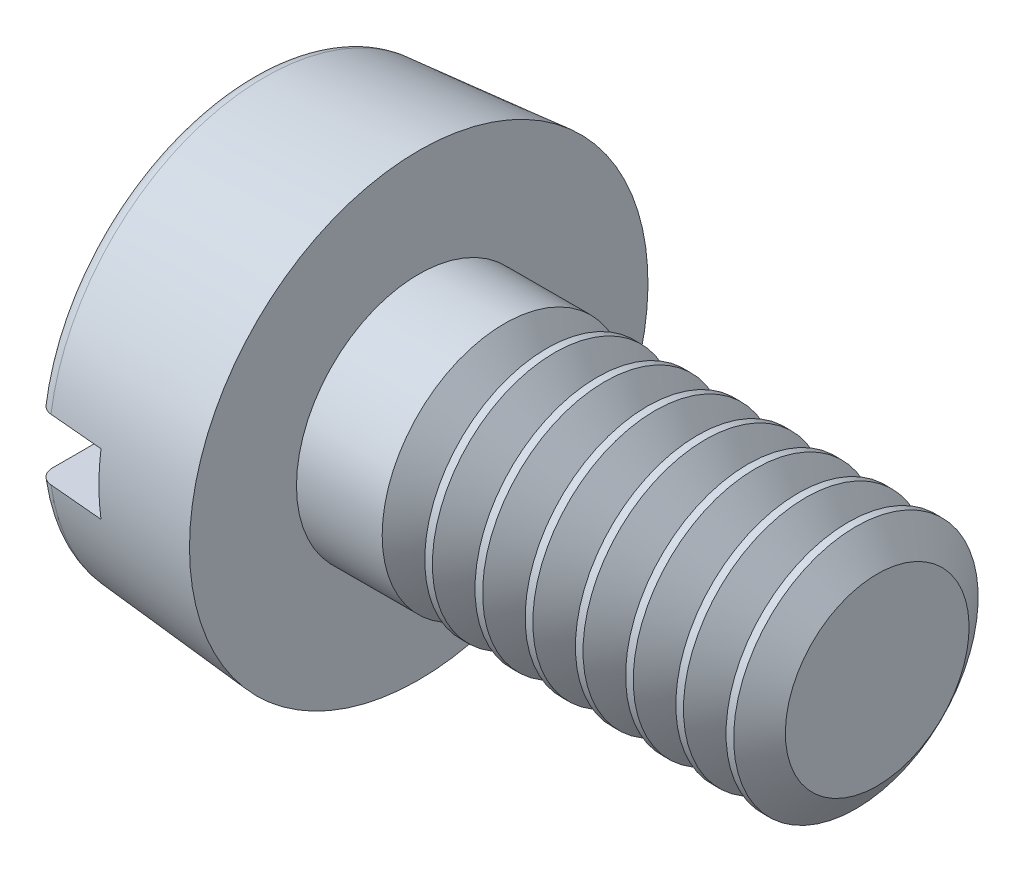
from build123d import *

# Parameters (mm, degrees)
FILLET2_R       = 0.1
SKETCH2_W       = 3
SKETCH2_H       = 0.4
SLOT_DEPTH      = 0.45
THDSCHPAT_COUNT = 8
THDSCHPAT_PITCH = 0.328571429


with BuildPart() as part:
    # BodySke → Base-Revolve (revolve)
    with BuildSketch(Plane.XY):
        Polygon((1.1, 0.8), (1.1, 1.5), (0, 1.40376247), (0, 0), (4.1, 0), (4.1, 0.8), align=None)
    revolve(axis=Axis((-25.4, 0, 0), (1, 0, 0)))

    # Fillet2
    fillet2_edges = [part.edges().sort_by_distance(p)[0] for p in [
        (0, -1.40376247, 0),
    ]]
    fillet(fillet2_edges, radius=FILLET2_R)

    # Sketch2 → Slot (cut)
    with BuildSketch(Plane(origin=(0, 0, 0), x_dir=(0, 0, -1), z_dir=(1, 0, 0))):
        Rectangle(SKETCH2_W, SKETCH2_H)
    extrude(amount=SLOT_DEPTH, mode=Mode.SUBTRACT)

    # ThdSchSke → ThreadSchematic (revolve, cut)
    with BuildSketch(Plane.XY):
        Polygon((1.8, -0.601), (1.6606587, -0.8), (1.6606587, -1), (1.9393413, -1), (1.9393413, -0.8), align=None)
    threadschematic = revolve(axis=Axis((-3.175, 0, 0), (1, 0, 0)), mode=Mode.SUBTRACT)

    # ThdSchPat: ThreadSchematic ×8
    with Locations(*[(i * THDSCHPAT_PITCH, 0, 0) for i in range(1, THDSCHPAT_COUNT)]):
        add(threadschematic, mode=Mode.SUBTRACT)


solid = part.part
